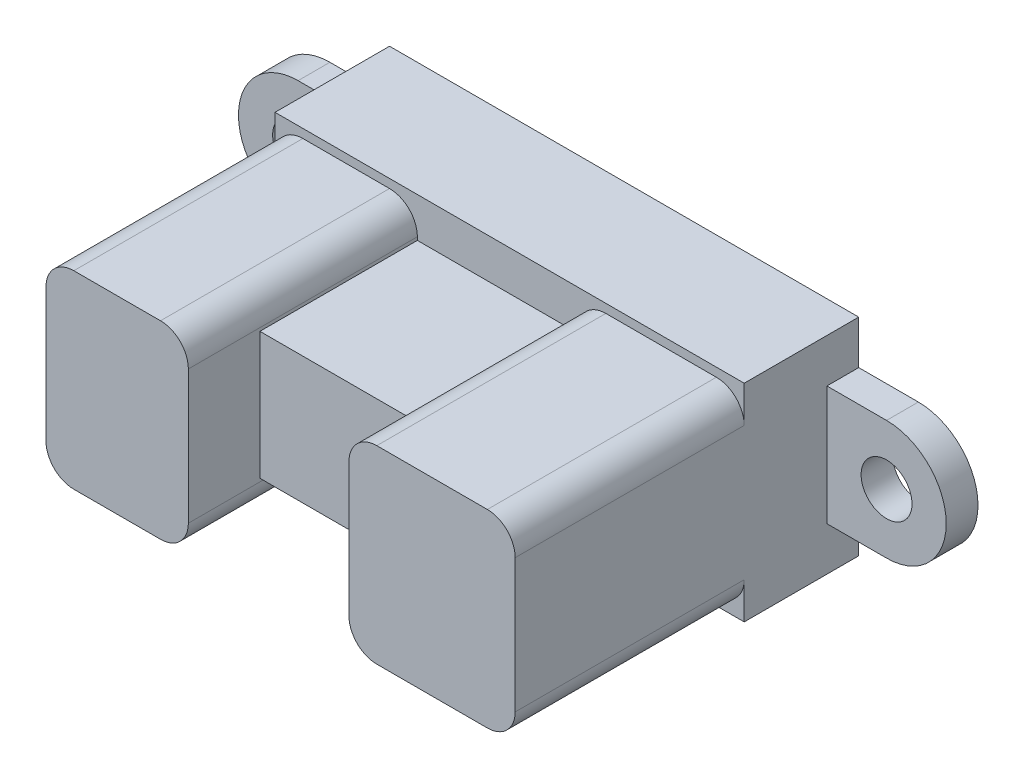
from build123d import *

# Parameters (mm, degrees)
CROQUIS1_R              = 1.6
SALIENTE_EXTRUIR1_DEPTH = 2
CROQUIS2_W              = 29.5
CROQUIS2_H              = 13
SALIENTE_EXTRUIR2_DEPTH = 7.2
CROQUIS3_W              = 10.1
CROQUIS3_H              = 8
SALIENTE_EXTRUIR3_DEPTH = 9.9
SALIENTE_EXTRUIR4_DEPTH = 4.5
CROQUIS5_W              = 10.1
CROQUIS5_H              = 1.2
SALIENTE_EXTRUIR5_DEPTH = 6
CROQUIS6_W              = 8
CROQUIS6_H              = 4.8
SALIENTE_EXTRUIR6_DEPTH = 5.9


with BuildPart() as part:
    # Croquis1 → Saliente-Extruir1 (new body)
    with BuildSketch(Plane.XY):
        with BuildLine():
            Line((18.5, -3.75), (-18.5, -3.75))
            ThreePointArc((-18.5, -3.75), (-22.25, 0), (-18.5, 3.75))
            Line((-18.5, 3.75), (18.5, 3.75))
            ThreePointArc((18.5, 3.75), (22.25, 0), (18.5, -3.75))
        make_face()
        with Locations((-18.5, 0)):
            Circle(CROQUIS1_R, mode=Mode.SUBTRACT)
        with Locations((18.5, 0)):
            Circle(CROQUIS1_R, mode=Mode.SUBTRACT)
    extrude(amount=SALIENTE_EXTRUIR1_DEPTH)

    # Croquis2 → Saliente-Extruir2 (add)
    with BuildSketch(Plane.XY):
        Rectangle(CROQUIS2_W, CROQUIS2_H)
    extrude(amount=SALIENTE_EXTRUIR2_DEPTH)

    # Croquis3 → Saliente-Extruir3 (add)
    with BuildSketch(Plane.XY.offset(7.2)):
        with BuildLine():
            ThreePointArc((-5.8, 4.2), (-6.312563133, 5.437436867), (-7.55, 5.95))
            Line((-7.55, 5.95), (-13, 5.95))
            ThreePointArc((-13, 5.95), (-14.237436867, 5.437436867), (-14.75, 4.2))
            Line((-14.75, 4.2), (-14.75, -4.2))
            ThreePointArc((-14.75, -4.2), (-14.237436867, -5.437436867), (-13, -5.95))
            Line((-13, -5.95), (-7.55, -5.95))
            ThreePointArc((-7.55, -5.95), (-6.312563133, -5.437436867), (-5.8, -4.2))
            Line((-5.8, -4.2), (-5.8, -4))
            Line((-5.8, -4), (-5.8, 4))
            Line((-5.8, 4), (-5.8, 4.2))
        make_face()
        with Locations((-0.75, 0)):
            Rectangle(CROQUIS3_W, CROQUIS3_H)
        with BuildLine():
            Line((4.3, 4.2), (4.3, 4))
            Line((4.3, 4), (4.3, -4))
            Line((4.3, -4), (4.3, -4.2))
            ThreePointArc((4.3, -4.2), (4.812563133, -5.437436867), (6.05, -5.95))
            Line((6.05, -5.95), (13, -5.95))
            ThreePointArc((13, -5.95), (14.237436867, -5.437436867), (14.75, -4.2))
            Line((14.75, -4.2), (14.75, 4.2))
            ThreePointArc((14.75, 4.2), (14.237436867, 5.437436867), (13, 5.95))
            Line((13, 5.95), (6.05, 5.95))
            ThreePointArc((6.05, 5.95), (4.812563133, 5.437436867), (4.3, 4.2))
        make_face()
    extrude(amount=SALIENTE_EXTRUIR3_DEPTH)

    # Croquis4 → Saliente-Extruir4 (add)
    with BuildSketch(Plane.XY.offset(17.1)):
        with BuildLine():
            Line((-5.8, -4), (-5.8, 4))
            Line((-5.8, 4), (-5.8, 4.2))
            ThreePointArc((-5.8, 4.2), (-6.312563133, 5.437436867), (-7.55, 5.95))
            Line((-7.55, 5.95), (-13, 5.95))
            ThreePointArc((-13, 5.95), (-14.237436867, 5.437436867), (-14.75, 4.2))
            Line((-14.75, 4.2), (-14.75, -4.2))
            ThreePointArc((-14.75, -4.2), (-14.237436867, -5.437436867), (-13, -5.95))
            Line((-13, -5.95), (-7.55, -5.95))
            ThreePointArc((-7.55, -5.95), (-6.312563133, -5.437436867), (-5.8, -4.2))
            Line((-5.8, -4.2), (-5.8, -4))
        make_face()
        with BuildLine():
            Line((4.3, 4), (4.3, -4))
            Line((4.3, -4), (4.3, -4.2))
            ThreePointArc((4.3, -4.2), (4.812563133, -5.437436867), (6.05, -5.95))
            Line((6.05, -5.95), (13, -5.95))
            ThreePointArc((13, -5.95), (14.237436867, -5.437436867), (14.75, -4.2))
            Line((14.75, -4.2), (14.75, 4.2))
            ThreePointArc((14.75, 4.2), (14.237436867, 5.437436867), (13, 5.95))
            Line((13, 5.95), (6.05, 5.95))
            ThreePointArc((6.05, 5.95), (4.812563133, 5.437436867), (4.3, 4.2))
            Line((4.3, 4.2), (4.3, 4))
        make_face()
    extrude(amount=SALIENTE_EXTRUIR4_DEPTH)

    # Croquis5 → Saliente-Extruir5 (add)
    with BuildSketch(Plane.XZ.offset(6.5)):
        with Locations((0, 3.9)):
            Rectangle(CROQUIS5_W, CROQUIS5_H)
    extrude(amount=SALIENTE_EXTRUIR5_DEPTH)

    # Croquis6 → Saliente-Extruir6 (add)
    with BuildSketch(Plane.XZ.offset(6.5)):
        with Locations((0, 6.9)):
            Rectangle(CROQUIS6_W, CROQUIS6_H)
    extrude(amount=SALIENTE_EXTRUIR6_DEPTH)


solid = part.part
